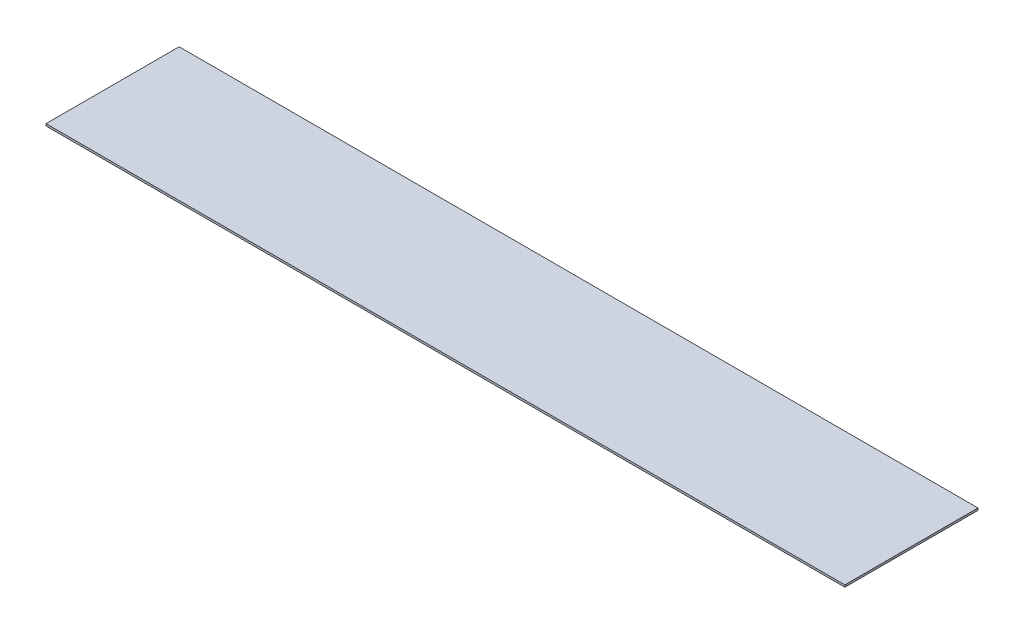
from build123d import *

# Parameters (mm, degrees)
SKETCH1_W           = 609.6
SKETCH1_H           = 101.6
BOSS_EXTRUDE1_DEPTH = 1.5875


with BuildPart() as part:
    # Sketch1 → Boss-Extrude1 (new body)
    with BuildSketch(Plane.XZ):
        with Locations((304.8, 50.8)):
            Rectangle(SKETCH1_W, SKETCH1_H)
    extrude(amount=BOSS_EXTRUDE1_DEPTH)


solid = part.part
